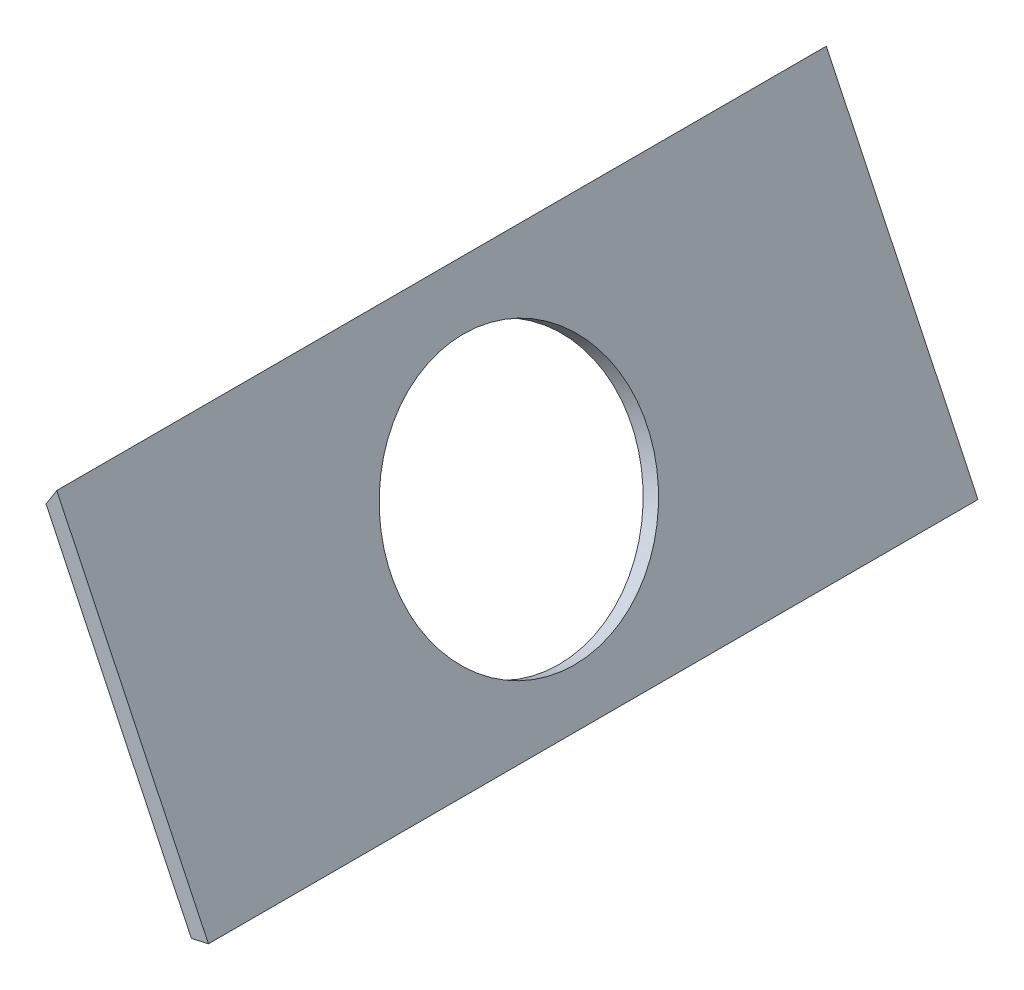
from build123d import *

# Parameters (mm, degrees)
AUFSATZ_LINEAR_AUSTRAGEN1_DEPTH  = 450
F_15_0_15_DURCHMESSER_BOHRUNG1_D = 150


with BuildPart() as part:
    # Skizze1 → Aufsatz-Linear austragen1 (new body)
    with BuildSketch(Plane.XY):
        Polygon((253.156995608, 264.02367356), (246.858259494, 254.02367356), (331.858259494, 76.52367356), (341.858259494, 78.794563683), align=None)
    extrude(amount=AUFSATZ_LINEAR_AUSTRAGEN1_DEPTH)

    # Ø15.0 (15) Durchmesser Bohrung1 (through all)
    with Locations(Plane(origin=(299.762083925, 143.548040189, 0), x_dir=(0, 0, 1), z_dir=(-0.901919134, -0.431904938, 0))):
        with Locations((225, 24.086944564)):
            Hole(F_15_0_15_DURCHMESSER_BOHRUNG1_D / 2)


solid = part.part
